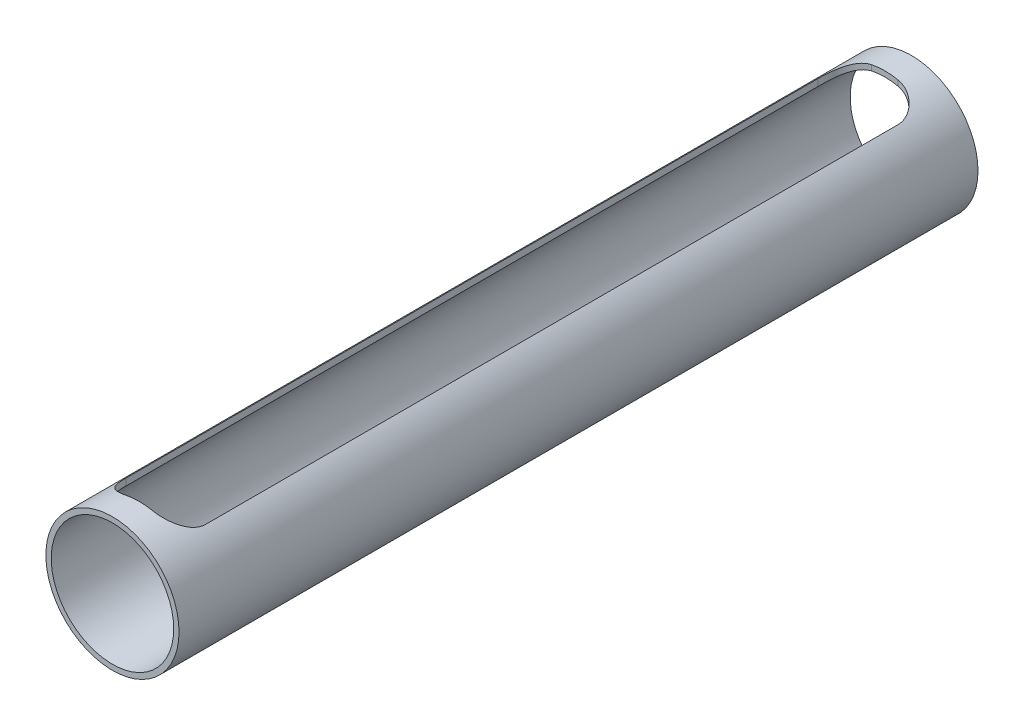
from build123d import *

# Parameters (mm, degrees)
SKETCH1_R           = 25
SKETCH1_R_2         = 23
BOSS_EXTRUDE1_DEPTH = 300
CUT_EXTRUDE1_DEPTH  = 51


with BuildPart() as part:
    # Sketch1 → Boss-Extrude1 (new body)
    with BuildSketch(Plane.XY):
        Circle(SKETCH1_R)
        Circle(SKETCH1_R_2, mode=Mode.SUBTRACT)
    extrude(amount=BOSS_EXTRUDE1_DEPTH)

    # Sketch2 → Cut-Extrude1 (cut)
    with BuildSketch(Plane(origin=(0, 50, 0), x_dir=(1, 0, 0), z_dir=(0, 1, 0))):
        with BuildLine():
            Line((5, -10), (-5, -10))
            ThreePointArc((-5, -10), (-12.071067812, -12.928932188), (-15, -20))
            Line((-15, -20), (-15, -280))
            ThreePointArc((-15, -280), (-12.071067812, -287.071067812), (-5, -290))
            Line((-5, -290), (5, -290))
            ThreePointArc((5, -290), (12.071067812, -287.071067812), (15, -280))
            Line((15, -280), (15, -20))
            ThreePointArc((15, -20), (12.071067812, -12.928932188), (5, -10))
        make_face()
    extrude(amount=-CUT_EXTRUDE1_DEPTH, mode=Mode.SUBTRACT)


solid = part.part
